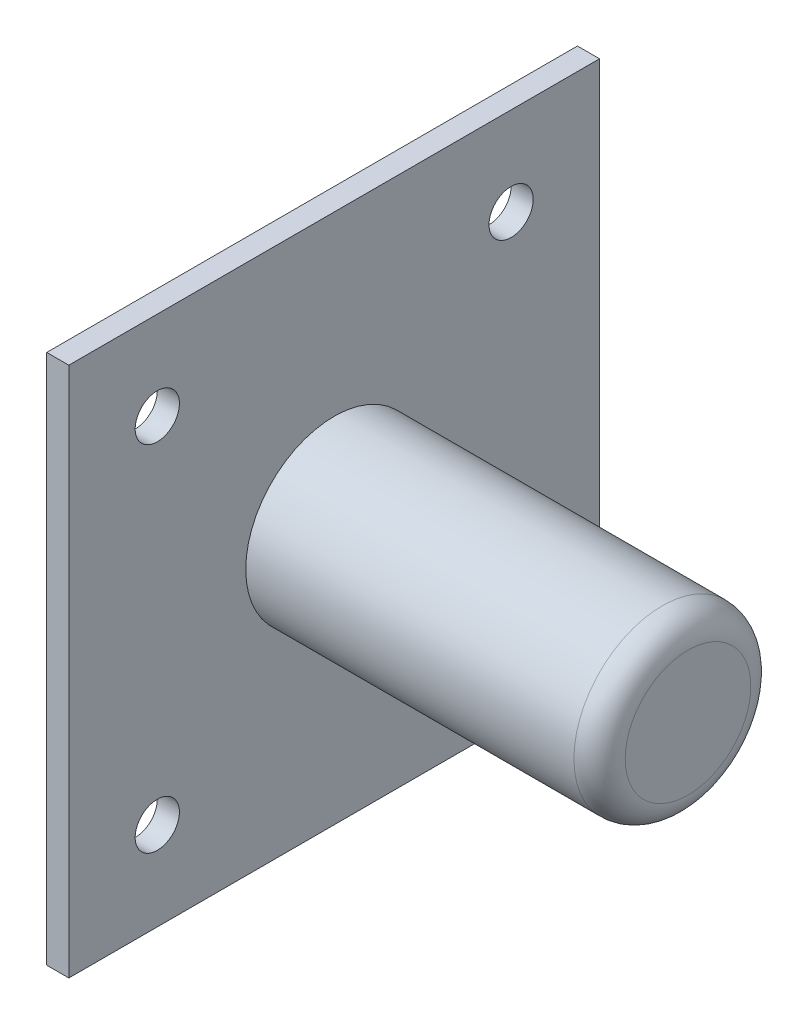
from build123d import *

# Parameters (mm, degrees)
SKETCH1_W           = 76.2
SKETCH1_H           = 76.2
SKETCH1_R           = 3.175
BOSS_EXTRUDE1_DEPTH = 1.5875


with BuildPart() as part:
    # Sketch1 → Boss-Extrude1 (new, symmetric)
    with BuildSketch(Plane(origin=(0, 0, 0), x_dir=(0, 0, -1), z_dir=(1, 0, 0))):
        Rectangle(SKETCH1_W, SKETCH1_H)
        with Locations((-25.4, 25.4)):
            Circle(SKETCH1_R, mode=Mode.SUBTRACT)
        with Locations((25.4, 25.4)):
            Circle(SKETCH1_R, mode=Mode.SUBTRACT)
        with Locations((25.4, -25.4)):
            Circle(SKETCH1_R, mode=Mode.SUBTRACT)
        with Locations((-25.4, -25.4)):
            Circle(SKETCH1_R, mode=Mode.SUBTRACT)
    extrude(amount=BOSS_EXTRUDE1_DEPTH, both=True)

    # Sketch2 → Revolve1 (revolve)
    with BuildSketch(Plane.XY, mode=Mode.PRIVATE) as revolve1_sk:
        with BuildLine():
            Line((48.70420202, 12.7), (1.5875, 12.7))
            Line((1.5875, 12.7), (1.5875, 0))
            Line((1.5875, 0), (52.3875, 0))
            Line((52.3875, 0), (52.3875, 9.01670202))
            ThreePointArc((52.3875, 9.01670202), (51.308686999, 11.621186999), (48.70420202, 12.7))
        make_face()
    revolve(revolve1_sk.sketch.rotate(Axis((1.5875, 0, 0), (1, 0, 0)), 90), axis=Axis((1.5875, 0, 0), (1, 0, 0)))


solid = part.part
